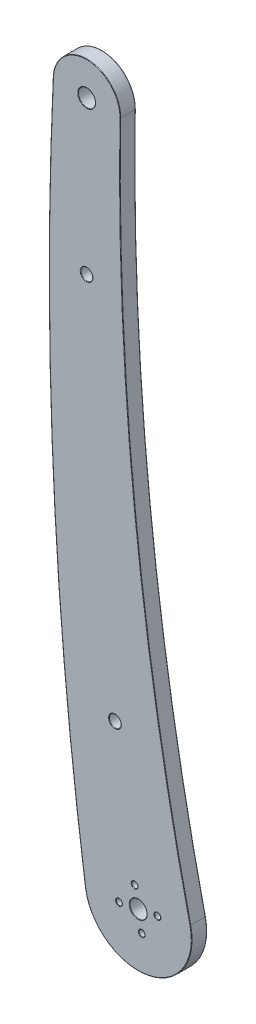
from build123d import *

# Parameters (mm, degrees)
SKETCH1_R           = 2.8
SKETCH1_R_2         = 1.95
SKETCH1_R_3         = 1
BOSS_EXTRUDE1_DEPTH = 5
FILLET1_R           = 0.15


with BuildPart() as part:
    # Sketch1 → Boss-Extrude1 (new body)
    with BuildSketch(Plane.XY):
        with BuildLine():
            ThreePointArc((-26.079167388, 278.756611768), (-21.239110839, 169.437578513), (-3.167903279, 61.513954424))
            ThreePointArc((-3.167903279, 61.513954424), (-17.024180678, 40.374281798), (-37.547403455, 55.128247669))
            ThreePointArc((-37.547403455, 55.128247669), (-48.065680098, 167.044655833), (-48.065582127, 279.454248661))
            ThreePointArc((-48.065582127, 279.454248661), (-36.728796341, 289.933495141), (-26.079167388, 278.756611768))
        make_face()
        with Locations((-20.22, 57.58)):
            Circle(SKETCH1_R, mode=Mode.SUBTRACT)
        with Locations((-37.077654746, 278.93902845)):
            Circle(SKETCH1_R, mode=Mode.SUBTRACT)
        with Locations((-37.107397794, 228.939037297)):
            Circle(SKETCH1_R_2, mode=Mode.SUBTRACT)
        with Locations((-27.821012361, 106.998868978)):
            Circle(SKETCH1_R_2, mode=Mode.SUBTRACT)
        with Locations((-19.053069402, 51.297454896)):
            Circle(SKETCH1_R_3, mode=Mode.SUBTRACT)
        with Locations((-26.502545104, 56.413069402)):
            Circle(SKETCH1_R_3, mode=Mode.SUBTRACT)
        with Locations((-21.386930598, 63.862545104)):
            Circle(SKETCH1_R_3, mode=Mode.SUBTRACT)
        with Locations((-13.937454896, 58.746930598)):
            Circle(SKETCH1_R_3, mode=Mode.SUBTRACT)
    extrude(amount=-BOSS_EXTRUDE1_DEPTH)

    # Fillet1
    fillet1_edges = [part.edges().sort_by_distance(p)[0] for p in [
        (-23.02, 57.58, -5),
        (-23.02, 57.58, 0),
        (-17.024180678, 40.374281798, -5),
        (-39.877654746, 278.93902845, -5),
        (-39.877654746, 278.93902845, 0),
        (-21.239110839, 169.437578513, -5),
        (-29.771012361, 106.998868978, -5),
        (-29.771012361, 106.998868978, 0),
        (-39.057397794, 228.939037297, -5),
        (-39.057397794, 228.939037297, 0),
        (-20.053069402, 51.297454896, -5),
        (-20.053069402, 51.297454896, 0),
        (-27.502545104, 56.413069402, -5),
        (-27.502545104, 56.413069402, 0),
        (-22.386930598, 63.862545104, -5),
        (-22.386930598, 63.862545104, 0),
        (-14.937454896, 58.746930598, -5),
        (-14.937454896, 58.746930598, 0),
        (-36.728796341, 289.933495141, -5),
        (-21.239110839, 169.437578513, 0),
        (-17.024180678, 40.374281798, 0),
        (-48.065680098, 167.044655833, 0),
        (-36.728796341, 289.933495141, 0),
        (-48.065680098, 167.044655833, -5),
    ]]
    fillet(fillet1_edges, radius=FILLET1_R)


solid = part.part
